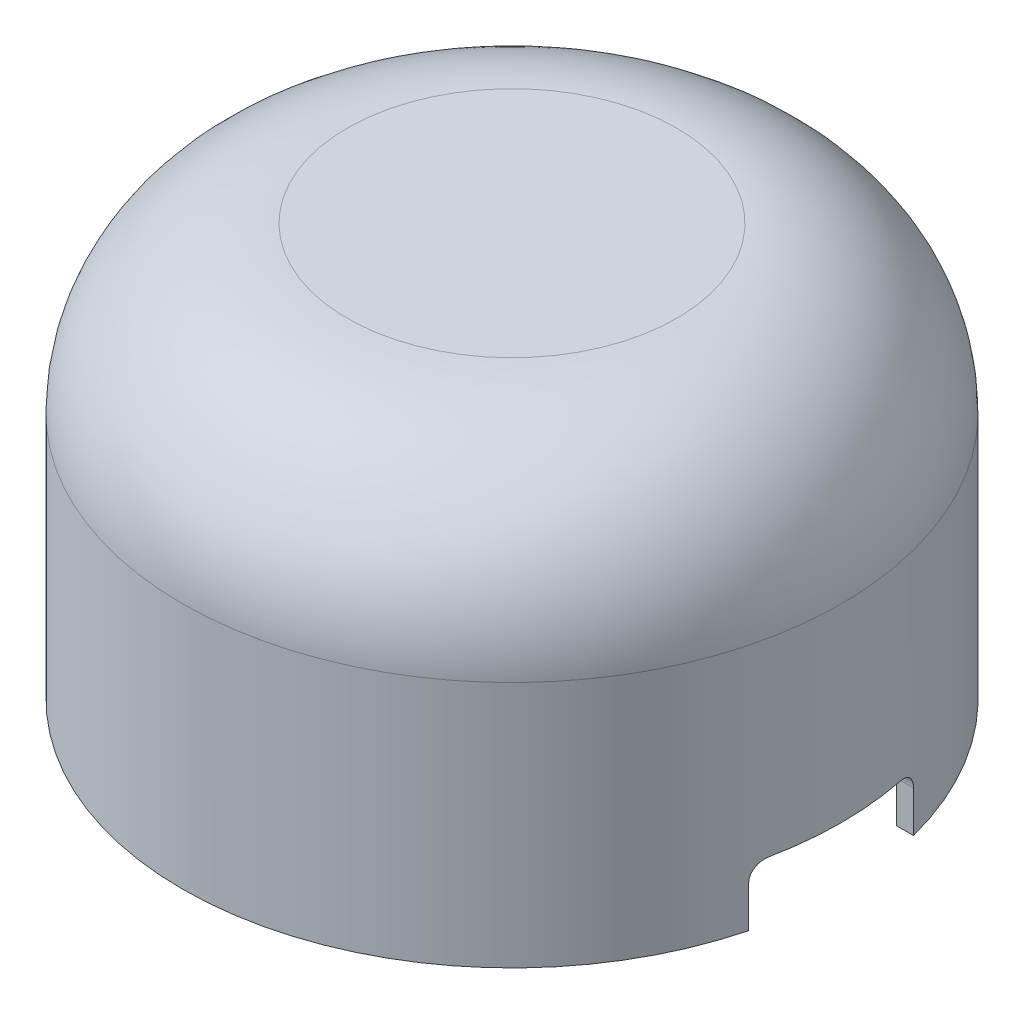
from build123d import *

# Parameters (mm, degrees)
SHELL1_T            = -2
SKETCH2_R           = 2.5
BOSS_EXTRUDE1_DEPTH = 55
CUT_EXTRUDE2_DEPTH  = 50


with BuildPart() as part:
    # Sketch1 → Revolve1 (revolve)
    with BuildSketch(Plane(origin=(0, 0, 0), x_dir=(0, 0, -1), z_dir=(1, 0, 0))):
        with BuildLine():
            Line((0, 0), (0, 50))
            Line((0, 50), (20, 50))
            ThreePointArc((20, 50), (34.142135624, 44.142135624), (40, 30))
            Line((40, 30), (40, 0))
            Line((40, 0), (0, 0))
        make_face()
    revolve(axis=Axis((0, 0, 0), (0, 1, 0)))

    # Shell1
    shell1_openings = [part.faces().sort_by_distance(p)[0] for p in [
        (0, 0, 0),
    ]]
    offset(amount=SHELL1_T, openings=shell1_openings, kind=Kind.INTERSECTION)

    # Sketch2 → Boss-Extrude1 (add)
    with BuildSketch(Plane.XZ.offset(-48)):
        with Locations(Location((0, 0, 0), (0, 0, 90))):
            Circle(SKETCH2_R)
    extrude(amount=BOSS_EXTRUDE1_DEPTH)

    # Sketch3 → Cut-Extrude2 (cut)
    with BuildSketch(Plane(origin=(6, 0, 0), x_dir=(0, 0, -1), z_dir=(1, 0, 0))):
        with BuildLine():
            Line((-10, 0), (10, 0))
            Line((10, 0), (10, 5))
            ThreePointArc((10, 5), (9.414213562, 6.414213562), (8, 7))
            Line((8, 7), (-8, 7))
            ThreePointArc((-8, 7), (-9.414213562, 6.414213562), (-10, 5))
            Line((-10, 5), (-10, 0))
        make_face()
    extrude(amount=CUT_EXTRUDE2_DEPTH, mode=Mode.SUBTRACT)


solid = part.part
